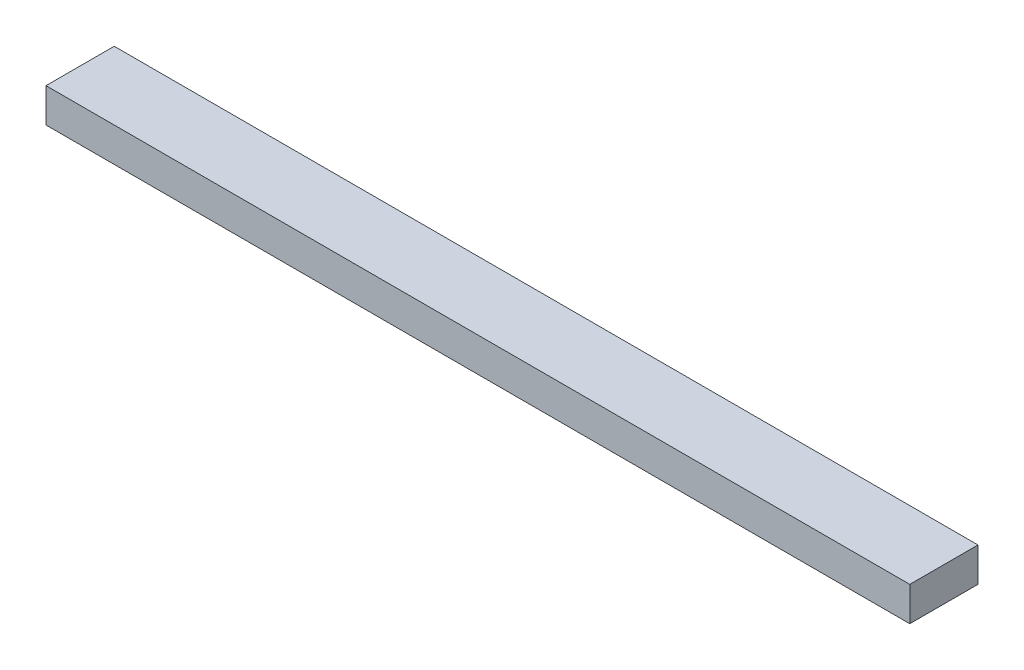
from build123d import *

# Parameters (mm, degrees)
SKETCH1_W           = 160.782
SKETCH1_H           = 12.7
BOSS_EXTRUDE1_DEPTH = 6.35


with BuildPart() as part:
    # Sketch1 → Boss-Extrude1 (new body)
    with BuildSketch(Plane(origin=(0, 0, 0), x_dir=(1, 0, 0), z_dir=(0, 1, 0))):
        Rectangle(SKETCH1_W, SKETCH1_H)
    extrude(amount=BOSS_EXTRUDE1_DEPTH)


solid = part.part
